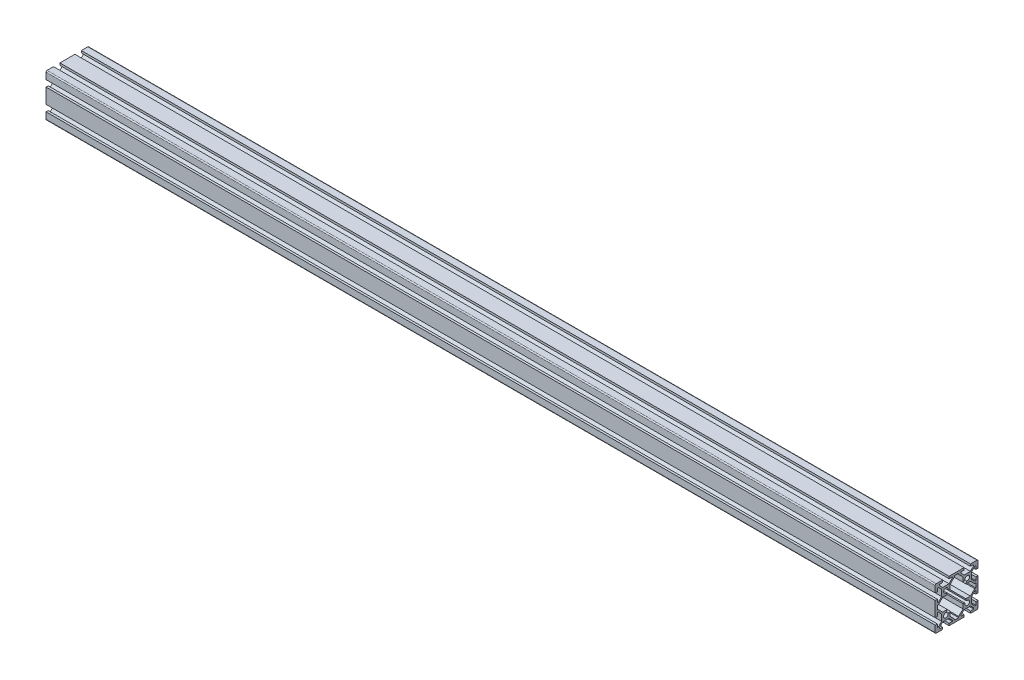
from build123d import *

# Parameters (mm, degrees)
BOSS_EXTRUDE1_DEPTH = 830


with BuildPart() as part:
    # Sketch1 → Boss-Extrude1 (new body)
    with BuildSketch(Plane(origin=(0, 0, 0), x_dir=(0, 0, -1), z_dir=(1, 0, 0))):
        with BuildLine():
            Line((-20, 19), (-20, 13))
            Line((-20, 13), (-18, 13))
            Line((-18, 13), (-18, 16))
            Line((-18, 16), (-17.060660172, 16))
            Line((-17.060660172, 16), (-14, 12.939339828))
            Line((-14, 12.939339828), (-14, 7.060660172))
            Line((-14, 7.060660172), (-17.060660172, 4))
            Line((-17.060660172, 4), (-18, 4))
            Line((-18, 4), (-18, 7))
            Line((-18, 7), (-20, 7))
            Line((-20, 7), (-20, -7))
            Line((-20, -7), (-18, -7))
            Line((-18, -7), (-18, -4))
            Line((-18, -4), (-17.060660172, -4))
            Line((-17.060660172, -4), (-14, -7.060660172))
            Line((-14, -7.060660172), (-14, -12.939339828))
            Line((-14, -12.939339828), (-17.060660172, -16))
            Line((-17.060660172, -16), (-18, -16))
            Line((-18, -16), (-18, -13))
            Line((-18, -13), (-20, -13))
            Line((-20, -13), (-20, -19))
            ThreePointArc((-20, -19), (-19.707106781, -19.707106781), (-19, -20))
            Line((-19, -20), (-13, -20))
            Line((-13, -20), (-13, -18))
            Line((-13, -18), (-16, -18))
            Line((-16, -18), (-16, -17.060660172))
            Line((-16, -17.060660172), (-12.939339828, -14))
            Line((-12.939339828, -14), (-7.060660172, -14))
            Line((-7.060660172, -14), (-4, -17.060660172))
            Line((-4, -17.060660172), (-4, -18))
            Line((-4, -18), (-7, -18))
            Line((-7, -18), (-7, -20))
            Line((-7, -20), (7, -20))
            Line((7, -20), (7, -18))
            Line((7, -18), (4, -18))
            Line((4, -18), (4, -17.060660172))
            Line((4, -17.060660172), (7.060660172, -14))
            Line((7.060660172, -14), (12.939339828, -14))
            Line((12.939339828, -14), (16, -17.060660172))
            Line((16, -17.060660172), (16, -18))
            Line((16, -18), (13, -18))
            Line((13, -18), (13, -20))
            Line((13, -20), (19, -20))
            ThreePointArc((19, -20), (19.707106781, -19.707106781), (20, -19))
            Line((20, -19), (20, -13))
            Line((20, -13), (18, -13))
            Line((18, -13), (18, -16))
            Line((18, -16), (17.060660172, -16))
            Line((17.060660172, -16), (14, -12.939339828))
            Line((14, -12.939339828), (14, -7.060660172))
            Line((14, -7.060660172), (17.060660172, -4))
            Line((17.060660172, -4), (18, -4))
            Line((18, -4), (18, -7))
            Line((18, -7), (20, -7))
            Line((20, -7), (20, 7))
            Line((20, 7), (18, 7))
            Line((18, 7), (18, 4))
            Line((18, 4), (17.060660172, 4))
            Line((17.060660172, 4), (14, 7.060660172))
            Line((14, 7.060660172), (14, 12.939339828))
            Line((14, 12.939339828), (17.060660172, 16))
            Line((17.060660172, 16), (18, 16))
            Line((18, 16), (18, 13))
            Line((18, 13), (20, 13))
            Line((20, 13), (20, 19))
            ThreePointArc((20, 19), (19.707106781, 19.707106781), (19, 20))
            Line((19, 20), (13, 20))
            Line((13, 20), (13, 18))
            Line((13, 18), (16, 18))
            Line((16, 18), (16, 17.060660172))
            Line((16, 17.060660172), (12.939339828, 14))
            Line((12.939339828, 14), (7.060660172, 14))
            Line((7.060660172, 14), (4, 17.060660172))
            Line((4, 17.060660172), (4, 18))
            Line((4, 18), (7, 18))
            Line((7, 18), (7, 20))
            Line((7, 20), (-7, 20))
            Line((-7, 20), (-7, 18))
            Line((-7, 18), (-4, 18))
            Line((-4, 18), (-4, 17.060660172))
            Line((-4, 17.060660172), (-7.060660172, 14))
            Line((-7.060660172, 14), (-12.939339828, 14))
            Line((-12.939339828, 14), (-16, 17.060660172))
            Line((-16, 17.060660172), (-16, 18))
            Line((-16, 18), (-13, 18))
            Line((-13, 18), (-13, 20))
            Line((-13, 20), (-19, 20))
            ThreePointArc((-19, 20), (-19.707106781, 19.707106781), (-20, 19))
        make_face()
        with BuildLine():
            Line((-16.939339828, 2), (-18, 2))
            Line((-18, 2), (-18, -2))
            Line((-18, -2), (-16.939339828, -2))
            Line((-16.939339828, -2), (-12.939339828, -6))
            Line((-12.939339828, -6), (-8.666662697, -6))
            Line((-8.666662697, -6), (-9.335919912, -8.007765667))
            ThreePointArc((-9.335919912, -8.007765667), (-11.48492424, -11.48492424), (-8.007765667, -9.335919912))
            Line((-8.007765667, -9.335919912), (-6, -8.666662697))
            Line((-6, -8.666662697), (-6, -12.939339828))
            Line((-6, -12.939339828), (-2, -16.939339828))
            Line((-2, -16.939339828), (-2, -18))
            Line((-2, -18), (2, -18))
            Line((2, -18), (2, -16.939339828))
            Line((2, -16.939339828), (6, -12.939339828))
            Line((6, -12.939339828), (6, -8.666662697))
            Line((6, -8.666662697), (8.007765667, -9.335919912))
            ThreePointArc((8.007765667, -9.335919912), (11.48492424, -11.48492424), (9.335919912, -8.007765667))
            Line((9.335919912, -8.007765667), (8.666662697, -6))
            Line((8.666662697, -6), (12.939339828, -6))
            Line((12.939339828, -6), (16.939339828, -2))
            Line((16.939339828, -2), (18, -2))
            Line((18, -2), (18, 2))
            Line((18, 2), (16.939339828, 2))
            Line((16.939339828, 2), (12.939339828, 6))
            Line((12.939339828, 6), (8.666662697, 6))
            Line((8.666662697, 6), (9.335919912, 8.007765667))
            ThreePointArc((9.335919912, 8.007765667), (11.48492424, 11.48492424), (8.007765667, 9.335919912))
            Line((8.007765667, 9.335919912), (6, 8.666662697))
            Line((6, 8.666662697), (6, 12.939339828))
            Line((6, 12.939339828), (2, 16.939339828))
            Line((2, 16.939339828), (2, 18))
            Line((2, 18), (-2, 18))
            Line((-2, 18), (-2, 16.939339828))
            Line((-2, 16.939339828), (-6, 12.939339828))
            Line((-6, 12.939339828), (-6, 8.666662697))
            Line((-6, 8.666662697), (-8.007765667, 9.335919912))
            ThreePointArc((-8.007765667, 9.335919912), (-11.48492424, 11.48492424), (-9.335919912, 8.007765667))
            Line((-9.335919912, 8.007765667), (-8.666662697, 6))
            Line((-8.666662697, 6), (-12.939339828, 6))
            Line((-12.939339828, 6), (-16.939339828, 2))
        make_face(mode=Mode.SUBTRACT)
    extrude(amount=BOSS_EXTRUDE1_DEPTH)


solid = part.part
